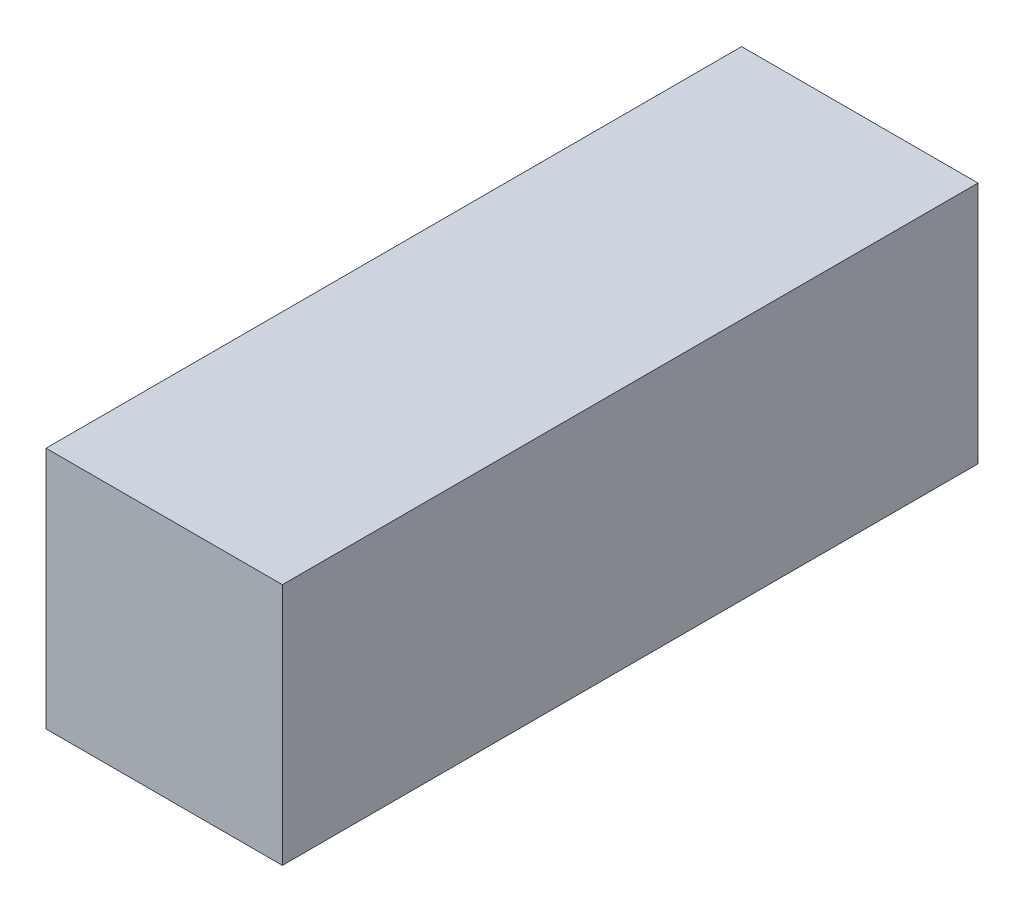
from build123d import *

# Parameters (mm, degrees)
SKETCH1_W           = 35
SKETCH1_H           = 36
BOSS_EXTRUDE1_DEPTH = 103


with BuildPart() as part:
    # Sketch1 → Boss-Extrude1 (new body)
    with BuildSketch(Plane.XY):
        Rectangle(SKETCH1_W, SKETCH1_H)
    extrude(amount=BOSS_EXTRUDE1_DEPTH)


solid = part.part
